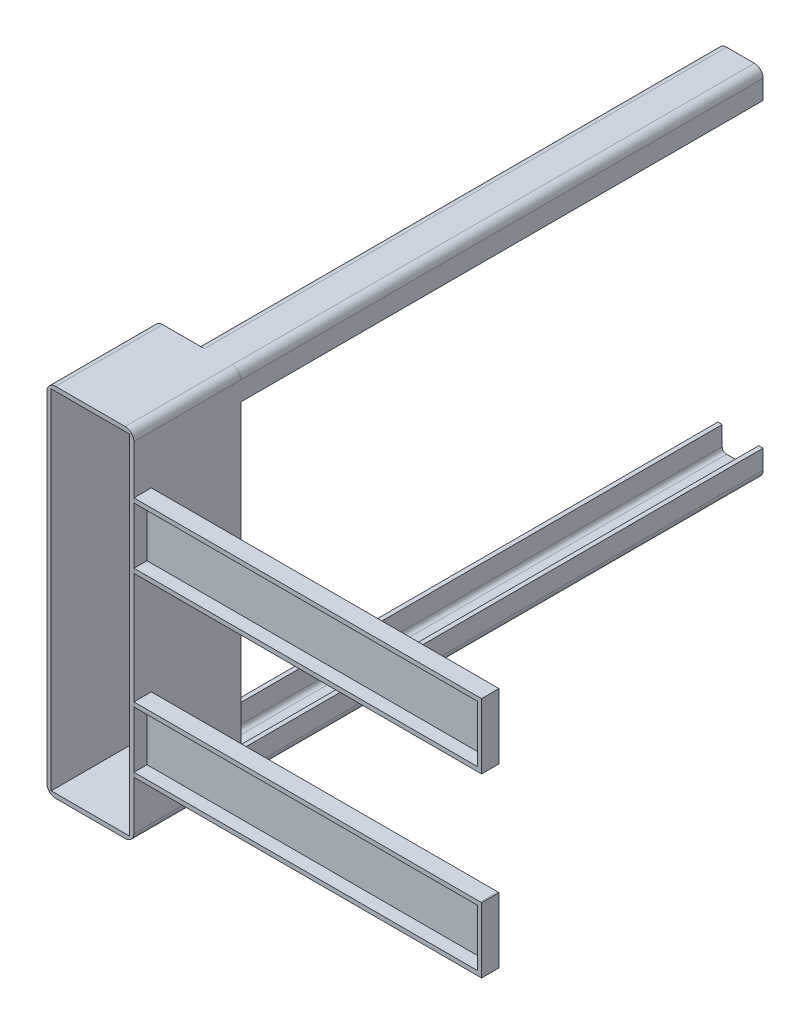
from build123d import *

# Parameters (mm, degrees)
BOSS_EXTRUDE1_DEPTH      = 600
BOSS_EXTRUDE1_2_DEPTH    = 600
BOSS_EXTRUDE2_DEPTH      = 123.00000000000001
SKETCH44_W               = 20
SKETCH44_H               = 75
BOSS_EXTRUDE16_DEPTH     = 399.5
BOSS_EXTRUDE16_2_DEPTH   = 399.5
BOSS_EXTRUDE17_DEPTH     = 278
CUT_EXTRUDE19_DEPTH      = 123
CUT_EXTRUDE20_DEPTH      = 118.00000000000001
SKETCH47_R               = 10.000000000000037
CUT_EXTRUDE21_DEPTH      = 278.00000000000006
SKETCH54_W               = 15
SKETCH54_H               = 65.00000000000001
SKETCH54_W_2             = 40.741333101316854
SKETCH54_H_2             = 65
CUT_EXTRUDE22_DEPTH      = 395.00000000000006
CUT_EXTRUDE25_DEPTH      = 72.00000000000004
CUT_EXTRUDE31_DEPTH      = 398.0000000000001
FILLET3_R                = 10
SKETCH56_R               = 3.500000000000001
SKETCH56_R_2             = 3.4999999999999996
CUT_EXTRUDE32_DEPTH      = 5
CUT_EXTRUDE33_DEPTH      = 940.5142755101579
CUT_EXTRUDE33_DEPTH_BACK = 940.5142755101579
BOSS_EXTRUDE18_DEPTH     = 5


with BuildPart() as part:
    # Sketch1 → Boss-Extrude1 (new body)
    with BuildSketch(Plane.XY):
        with BuildLine():
            Line((-20.999999999999996, 173.00000000000003), (-26.000000000000014, 173.00000000000003))
            Line((-26.000000000000014, 173.00000000000003), (-26.00000000000001, 195))
            ThreePointArc((-26.00000000000001, 195), (-23.071067811865483, 202.07106781186548), (-16.00000000000001, 205.00000000000003))
            Line((-16.00000000000001, 205.00000000000003), (15.999999999999996, 205.00000000000003))
            ThreePointArc((15.999999999999996, 205.00000000000003), (23.071067811865476, 202.07106781186548), (26.000000000000004, 195))
            Line((26.000000000000004, 195), (26.000000000000007, 173.00000000000003))
            Line((26.000000000000007, 173.00000000000003), (20.999999999999996, 173.00000000000003))
            Line((20.999999999999996, 173.00000000000003), (20.999999999999996, 195))
            ThreePointArc((20.999999999999996, 195), (19.535533905932738, 198.53553390593274), (16, 200))
            Line((16, 200), (-16, 200))
            ThreePointArc((-16, 200), (-19.535533905932738, 198.53553390593274), (-20.999999999999996, 195))
            Line((-20.999999999999996, 195), (-20.999999999999996, 173.00000000000003))
        make_face()
    extrude(amount=BOSS_EXTRUDE1_DEPTH)

    # Sketch2 → Boss-Extrude2 (add)
    with BuildSketch(Plane.XY.offset(600)):
        Polygon((26.000000000000004, 205.00000000000003), (-74.00000000000001, 205.00000000000003), (-73.99999999999996, -205.00000000000003), (26.000000000000053, -205.00000000000003), align=None)
    extrude(amount=BOSS_EXTRUDE2_DEPTH)

    # Sketch37 → Cut-Extrude19 (cut)
    with BuildSketch(Plane(origin=(0, 0, 600), x_dir=(-1, 0, 0), z_dir=(0, 0, -1))):
        with BuildLine():
            ThreePointArc((59.99999999999997, -142), (57.071067811865426, -134.9289321881345), (49.999999999999915, -132))
            Line((49.99999999999997, -132), (49.99999999999997, -142))
            Line((49.99999999999997, -142), (39.99999999999997, -142))
            ThreePointArc((39.99999999999997, -142), (49.99999999999997, -152), (59.99999999999997, -142))
        make_face()
        with BuildLine():
            Line((49.99999999999997, -142), (49.99999999999997, -132))
            ThreePointArc((49.999999999999915, -132), (42.928932188134475, -134.92893218813455), (39.99999999999997, -142))
            Line((39.99999999999997, -142), (49.99999999999997, -142))
        make_face()
        with BuildLine():
            ThreePointArc((5.999999999999988, -142), (3.0710678118654364, -134.9289321881345), (-4.00000000000009, -131.99999999999997))
            Line((-4.000000000000029, -131.99999999999997), (-4.000000000000028, -142))
            Line((-4.000000000000028, -142), (5.999999999999988, -142))
        make_face()
        with BuildLine():
            Line((-4.000000000000028, -142), (-4.000000000000029, -131.99999999999997))
            ThreePointArc((-4.00000000000009, -131.99999999999997), (-11.071067811865493, -149.0710678118655), (5.999999999999988, -142))
            Line((5.999999999999988, -142), (-4.000000000000028, -142))
        make_face()
        with BuildLine():
            ThreePointArc((59.99999999999996, 54.00000000000002), (49.99999999999996, 64.00000000000003), (39.99999999999996, 54.00000000000002))
            Line((39.99999999999996, 54.00000000000002), (49.99999999999996, 54.00000000000002))
            Line((49.99999999999996, 54.00000000000002), (49.99999999999996, 44.00000000000002))
            ThreePointArc((49.9999999999999, 44.00000000000002), (57.07106781186541, 46.928932188134524), (59.99999999999996, 54.00000000000002))
        make_face()
        with BuildLine():
            Line((49.99999999999996, 54.00000000000002), (39.99999999999996, 54.00000000000002))
            ThreePointArc((39.99999999999996, 54.00000000000002), (42.92893218813446, 46.92893218813457), (49.9999999999999, 44.00000000000002))
            Line((49.99999999999996, 44.00000000000002), (49.99999999999996, 54.00000000000002))
        make_face()
        with BuildLine():
            Line((-4.0000000000000515, 44.00000000000001), (-4.000000000000052, 54.00000000000002))
            Line((-4.000000000000052, 54.00000000000002), (5.999999999999964, 54.00000000000002))
            ThreePointArc((5.999999999999964, 54.00000000000002), (-11.071067811865518, 61.071067811865525), (-4.0000000000001075, 44.00000000000001))
        make_face()
        with BuildLine():
            Line((5.999999999999964, 54.00000000000002), (-4.000000000000052, 54.00000000000002))
            Line((-4.000000000000052, 54.00000000000002), (-4.0000000000000515, 44.00000000000001))
            ThreePointArc((-4.0000000000001075, 44.00000000000001), (3.0710678118654133, 46.92893218813452), (5.999999999999964, 54.00000000000002))
        make_face()
    extrude(amount=-CUT_EXTRUDE19_DEPTH, mode=Mode.SUBTRACT)

    # Sketch43 → Cut-Extrude20 (cut)
    with BuildSketch(Plane.XY.offset(723)):
        Polygon((-69, 200), (21.00000000000015, 200), (21.0000000000002, -200), (-68.99999999999994, -200), align=None)
    extrude(amount=-CUT_EXTRUDE20_DEPTH, mode=Mode.SUBTRACT)

    # Fillet3
    fillet3_edges = [part.edges().sort_by_distance(p)[0] for p in [
        (26.000000000000053, -205.00000000000003, 661.5),
        (26.000000000000004, 205.00000000000003, 661.5),
        (-74.00000000000001, 205.00000000000003, 661.5),
        (-73.99999999999996, -205.00000000000003, 661.5),
    ]]
    fillet(fillet3_edges, radius=FILLET3_R)

    # Sketch56 → Cut-Extrude32 (cut)
    with BuildSketch(Plane.XY.offset(605)):
        with Locations((-52.97440145114139, 18.72481387938563)):
            Circle(SKETCH56_R)
        with Locations((4.974401451080079, 18.72481387938569)):
            Circle(SKETCH56_R_2)
        with Locations((-52.97440145114128, -67.83819138977199)):
            Circle(SKETCH56_R)
        with Locations((4.974401451080149, -67.83819138977194)):
            Circle(SKETCH56_R)
    extrude(amount=-CUT_EXTRUDE32_DEPTH, mode=Mode.SUBTRACT)


with BuildPart() as body_2:
    # Sketch1 → Boss-Extrude1 2 (new body)
    with BuildSketch(Plane.XY):
        with BuildLine():
            Line((26.000000000000004, -195), (26.000000000000007, -173.00000000000003))
            Line((26.000000000000007, -173.00000000000003), (20.999999999999996, -173.00000000000003))
            Line((20.999999999999996, -173.00000000000003), (20.999999999999996, -195))
            ThreePointArc((20.999999999999996, -195), (19.535533905932738, -198.53553390593274), (16, -200))
            Line((16, -200), (-16, -200))
            ThreePointArc((-16, -200), (-19.53553390593274, -198.53553390593274), (-20.999999999999996, -195))
            Line((-20.999999999999996, -195), (-20.999999999999996, -173.00000000000003))
            Line((-20.999999999999996, -173.00000000000003), (-26.000000000000014, -173.00000000000003))
            Line((-26.000000000000014, -173.00000000000003), (-26.00000000000001, -195))
            ThreePointArc((-26.00000000000001, -195), (-23.071067811865486, -202.07106781186548), (-16.00000000000001, -205.00000000000003))
            Line((-16.00000000000001, -205.00000000000003), (15.999999999999996, -205.00000000000003))
            ThreePointArc((15.999999999999996, -205.00000000000003), (23.071067811865476, -202.07106781186548), (26.000000000000004, -195))
        make_face()
    extrude(amount=BOSS_EXTRUDE1_2_DEPTH)


with BuildPart() as body_3:
    # Sketch44 → Boss-Extrude16 (new body)
    with BuildSketch(Plane(origin=(26.000000000000032, 4.1e-15, 0), x_dir=(0, 0, -1), z_dir=(1, 0, 0))):
        with Locations((-713, -101.5)):
            Rectangle(SKETCH44_W, SKETCH44_H)
    extrude(amount=BOSS_EXTRUDE16_DEPTH)



with BuildPart() as body_4:
    # Sketch44 → Boss-Extrude16 2 (new body)
    with BuildSketch(Plane(origin=(26.000000000000032, 4.1e-15, 0), x_dir=(0, 0, -1), z_dir=(1, 0, 0))):
        with Locations((-713, 101.5)):
            Rectangle(SKETCH44_W, SKETCH44_H)
    extrude(amount=BOSS_EXTRUDE16_2_DEPTH)


with BuildPart() as body_3_1:
    add(body_3.part)

    add(body_4.part)  # Boss-Extrude17 merges body 4
    # Sketch45 → Boss-Extrude17 (add)
    with BuildSketch(Plane(origin=(0, 139, 0), x_dir=(1, 0, 0), z_dir=(0, 1, 0))):
        with BuildLine():
            Line((310.05762353332216, -763.741333101317), (374.4423764666778, -763.741333101317))
            ThreePointArc((374.4423764666778, -763.741333101317), (380.77084556976007, -729.2229662434094), (357.44868415357087, -703.0000000000001))
            Line((357.44868415357087, -703.0000000000001), (327.05131584642913, -703.0000000000001))
            ThreePointArc((327.05131584642913, -703.0000000000001), (303.72915443024, -729.2229662434092), (310.05762353332216, -763.741333101317))
        make_face()
    extrude(amount=-BOSS_EXTRUDE17_DEPTH)

    # Sketch47 → Cut-Extrude21 (cut)
    with BuildSketch(Plane(origin=(0, 139, 0), x_dir=(1, 0, 0), z_dir=(0, 1, 0))):
        with Locations(Location((342.25, -740, 0), (0, 0, 270))):
            Circle(SKETCH47_R)
    extrude(amount=-CUT_EXTRUDE21_DEPTH, mode=Mode.SUBTRACT)

    # Sketch54 → Cut-Extrude22 (cut)
    with BuildSketch(Plane(origin=(26.000000000000032, 4.1e-15, 0), x_dir=(0, 0, -1), z_dir=(1, 2.3e-16, 0))):
        Polygon((-723, -134.00000000000009), (-723, -69.00000000000009), (-767.5036408731896, -69.00000000000007), (-767.5036408731896, -134.00000000000009), align=None)
        with Locations((-715.5, -101.50000000000009)):
            Rectangle(SKETCH54_W, SKETCH54_H)
        with Locations((-743.3706665506584, 101.49999999999991)):
            Rectangle(SKETCH54_W_2, SKETCH54_H_2)
        with Locations((-715.5, 101.49999999999991)):
            Rectangle(SKETCH54_W, SKETCH54_H_2)
    extrude(amount=CUT_EXTRUDE22_DEPTH, mode=Mode.SUBTRACT)

    # Sketch50 → Cut-Extrude25 (cut)
    with BuildSketch(Plane(origin=(0, 0, 703), x_dir=(-1, 0, 0), z_dir=(0, 0, -1))):
        Polygon((-383.7500000000001, 69.00000000000006), (-300.75, 69.00000000000006), (-300.75, 134.00000000000006), (-383.75000000000006, 134.00000000000006), align=None)
        Polygon((-383.7500000000001, -69.00000000000014), (-300.75, -69.00000000000011), (-300.74999999999994, -134.0000000000001), (-383.75, -134.00000000000017), align=None)
    extrude(amount=-CUT_EXTRUDE25_DEPTH, mode=Mode.SUBTRACT)

    # Sketch55 → Cut-Extrude31 (cut)
    with BuildSketch(Plane(origin=(26.000000000000032, 4.1e-15, 0), x_dir=(0, 0, -1), z_dir=(1, 2.3e-16, 0))):
        Polygon((-703, 63.99999999999991), (-763.741333101317, 63.99999999999989), (-763.741333101317, -64.00002686930748), (-703, -64.00002686930746), align=None)
    extrude(amount=CUT_EXTRUDE31_DEPTH, mode=Mode.SUBTRACT)


with BuildPart() as cut_extrude31_piece_1:
    # of the separate pieces the step leaves, piece 1, a body of its own (cut_extrude31_pieces)
    add(body_3_1.part.solids().sort_by_distance((306.04226602, 69, 723))[0])


with BuildPart() as cut_extrude31_piece_2:
    # of the separate pieces the step leaves, piece 2, a body of its own (cut_extrude31_pieces)
    add(body_3_1.part.solids().sort_by_distance((26, -139, 723))[0])


with BuildPart() as cut_extrude33_tool:
    # Sketch57 → Cut-Extrude33 (new, two sides: drawn at the far end of the back side and taken through both)
    with BuildSketch(Plane.XZ.offset(139).offset(-CUT_EXTRUDE33_DEPTH_BACK)):
        with BuildLine():
            Line((306.04226601953667, 723), (378.45773398046333, 723))
            ThreePointArc((378.45773398046333, 723), (382.05713294138866, 743.923285228811), (374.4423764666778, 763.741333101317))
            Line((374.4423764666778, 763.741333101317), (310.05762353332216, 763.741333101317))
            ThreePointArc((310.05762353332216, 763.741333101317), (302.4428670586113, 743.923285228811), (306.04226601953667, 723))
        make_face()
    extrude(amount=CUT_EXTRUDE33_DEPTH + CUT_EXTRUDE33_DEPTH_BACK)


with BuildPart() as cut_extrude31_piece_1_1:
    add(cut_extrude31_piece_1.part)

    # Cut-Extrude33: cut by cut_extrude33_tool
    add(cut_extrude33_tool.part, mode=Mode.SUBTRACT)



with BuildPart() as cut_extrude31_piece_2_1:
    add(cut_extrude31_piece_2.part)

    # Cut-Extrude33: cut by cut_extrude33_tool
    add(cut_extrude33_tool.part, mode=Mode.SUBTRACT)


with BuildPart() as cut_extrude31_piece_1_2:
    add(cut_extrude31_piece_1_1.part)

    add(cut_extrude31_piece_2_1.part)  # Boss-Extrude18 merges Cut-Extrude31 piece 2
    # Sketch58 → Boss-Extrude18 (add)
    with BuildSketch(Plane(origin=(0, 0, 703), x_dir=(-1, 0, 0), z_dir=(0, 0, -1))):
        Polygon((-383.7500000000001, -69.00000000000014), (-300.75, -69.00000000000011), (-300.74999999999994, -134.0000000000001), (-383.75, -134.00000000000017), align=None)
        Polygon((-383.75000000000006, 134.00000000000006), (-300.75, 134.00000000000006), (-300.75, 69.00000000000006), (-383.7500000000001, 69.00000000000006), align=None)
    extrude(amount=-BOSS_EXTRUDE18_DEPTH)


solid = Compound([part.part, body_2.part, cut_extrude31_piece_1_2.part])
